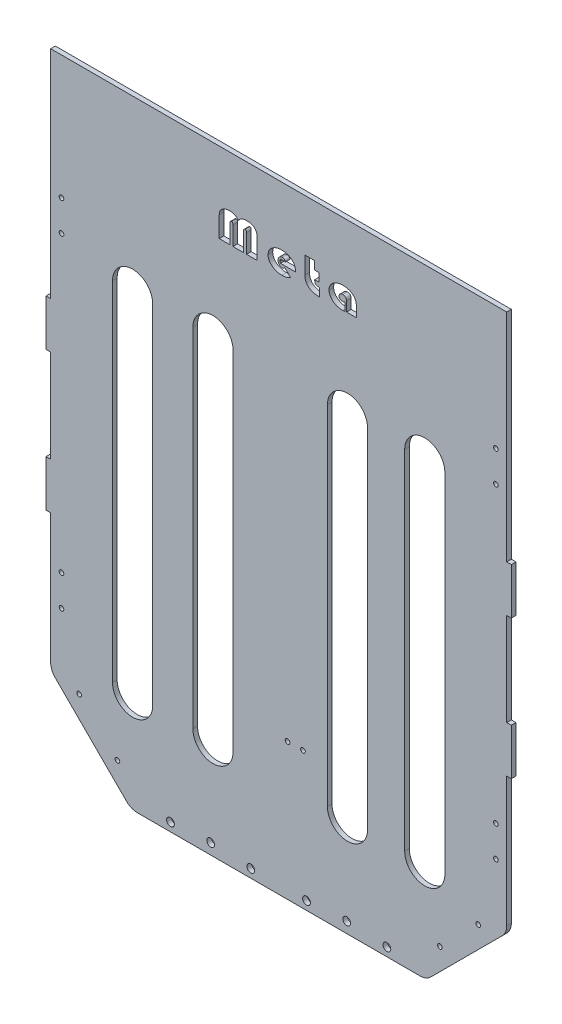
from build123d import *

# Parameters (mm, degrees)
EXTRUDE_1_DEPTH     = 3
CUT_EXTRUDE_2_DEPTH = 4
SKETCH_4_R          = 1.5
CUT_EXTRUDE_3_DEPTH = 4
CUT_EXTRUDE_4_DEPTH = 4
FILLET_3_R          = 10
SKETCH_8_R          = 1.5
CUT_EXTRUDE_5_DEPTH = 4
SKETCH_9_W          = 295
SKETCH_9_H          = 60
EXTRUDE_2_DEPTH     = 3
SKETCH_10_R         = 1.5
CUT_EXTRUDE_6_DEPTH = 10
CUT_EXTRUDE_7_DEPTH = 10
SKETCH_13_R         = 2.5
CUT_EXTRUDE_8_DEPTH = 10


with BuildPart() as part:
    # 草图1 → 凸台-拉伸1 (new body)
    with BuildSketch(Plane.XY):
        Polygon((-147.5, 90), (-150.5, 90), (-150.5, 60), (-147.5, 60), (-147.5, 0), (-150.5, 0), (-150.5, -30), (-147.5, -30), (-147.5, -90), (-147.5, -120), (-147.5, -170), (147.5, -170), (147.5, -120), (147.5, -90), (147.5, -30), (150.5, -30), (150.5, 0), (147.5, 0), (147.5, 60), (150.5, 60), (150.5, 90), (147.5, 90), (147.5, 170), (-147.5, 170), align=None)
    extrude(amount=EXTRUDE_1_DEPTH)

    # 草图3 → 切除-拉伸2 (cut, through all)
    with BuildSketch(Plane.XY.offset(3)):
        Polygon((-147.5, -118), (-95.5, -170), (-147.5, -170), align=None)
        Polygon((147.5, -170), (147.5, -118), (95.5, -170), align=None)
    extrude(amount=-CUT_EXTRUDE_2_DEPTH, mode=Mode.SUBTRACT)

    # 草图4 → 切除-拉伸3 (cut, through all)
    with BuildSketch(Plane.XY.offset(3)):
        with Locations((140.5, 150)):
            Circle(SKETCH_4_R)
        with Locations((140.5, 130)):
            Circle(SKETCH_4_R)
        with Locations((140.5, -60)):
            Circle(SKETCH_4_R)
        with Locations((140.5, -80)):
            Circle(SKETCH_4_R)
        with Locations((-140.5, -80)):
            Circle(SKETCH_4_R)
        with Locations((-140.5, -60)):
            Circle(SKETCH_4_R)
        with Locations((-140.5, 130)):
            Circle(SKETCH_4_R)
        with Locations((-140.5, 150)):
            Circle(SKETCH_4_R)
    extrude(amount=-CUT_EXTRUDE_3_DEPTH, mode=Mode.SUBTRACT)

    # 草图5 → 切除-拉伸4 (cut, through all)
    with BuildSketch(Plane.XY.offset(3)):
        with BuildLine():
            Line((-81.5, 120), (-81.5, -105))
            ThreePointArc((-81.5, -105), (-94.5, -118), (-107.5, -105))
            Line((-107.5, -105), (-107.5, 120))
            ThreePointArc((-107.5, 120), (-94.5, 133), (-81.5, 120))
        make_face()
        with BuildLine():
            Line((-29.5, 120), (-29.5, -105))
            ThreePointArc((-29.5, -105), (-42.5, -118), (-55.5, -105))
            Line((-55.5, -105), (-55.5, 120))
            ThreePointArc((-55.5, 120), (-42.5, 133), (-29.5, 120))
        make_face()
        with BuildLine():
            Line((57.5, 120), (57.5, -105))
            ThreePointArc((57.5, -105), (44.5, -118), (31.5, -105))
            Line((31.5, -105), (31.5, 120))
            ThreePointArc((31.5, 120), (44.5, 133), (57.5, 120))
        make_face()
        with BuildLine():
            Line((107.5, 120), (107.5, -105))
            ThreePointArc((107.5, -105), (94.5, -118), (81.5, -105))
            Line((81.5, -105), (81.5, 120))
            ThreePointArc((81.5, 120), (94.5, 133), (107.5, 120))
        make_face()
    extrude(amount=-CUT_EXTRUDE_4_DEPTH, mode=Mode.SUBTRACT)

    # 圆角3
    fillet_3_edges = [part.edges().sort_by_distance(p)[0] for p in [
        (-147.5, -118, 1.5),
        (-95.5, -170, 1.5),
        (95.5, -170, 1.5),
        (147.5, -118, 1.5),
    ]]
    fillet(fillet_3_edges, radius=FILLET_3_R)

    # 草图8 → 切除-拉伸5 (cut, through all)
    with BuildSketch(Plane.XY.offset(3)):
        with Locations((-129.044105664, -122.313758713)):
            Circle(SKETCH_8_R)
        with Locations((-104.295368322, -147.062496054)):
            Circle(SKETCH_8_R)
        with Locations((104.295368322, -147.062496054)):
            Circle(SKETCH_8_R)
        with Locations((129.044105664, -122.313758713)):
            Circle(SKETCH_8_R)
    extrude(amount=-CUT_EXTRUDE_5_DEPTH, mode=Mode.SUBTRACT)

    # 草图9 → 凸台-拉伸2 (add)
    with BuildSketch(Plane.XY.offset(3)):
        with Locations((0, 200)):
            Rectangle(SKETCH_9_W, SKETCH_9_H)
    extrude(amount=-EXTRUDE_2_DEPTH)

    # 草图10 → 切除-拉伸6 (cut)
    with BuildSketch(Plane(origin=(0, 0, 0), x_dir=(-1, 0, 0), z_dir=(0, 0, -1))):
        with Locations((-15.714480525, -81.497694715)):
            Circle(SKETCH_10_R)
        with Locations((-5.714480525, -81.497694715)):
            Circle(SKETCH_10_R)
    extrude(amount=-CUT_EXTRUDE_6_DEPTH, mode=Mode.SUBTRACT)

    # 草图12 → 切除-拉伸7 (cut)
    with BuildSketch(Plane.XY.offset(3)):
        with BuildLine():
            Line((-38.459270455, 178.142606867), (-38.459270455, 191.48003622))
            add(Edge.make_bspline(
                [(-38.459270455, 191.48003622), (-38.455033411, 191.681058058), (-38.446709584, 192.075972675), (-38.346599974, 192.652647807), (-38.208715022, 193.205847545), (-37.99443122, 193.725817353), (-37.730436968, 194.22146777), (-37.396648893, 194.680992182), (-37.014003649, 195.120623841), (-36.567844802, 195.521180351), (-36.079300876, 195.888824271), (-35.54992644, 196.206329747), (-34.989033735, 196.477067178), (-34.392513082, 196.697756907), (-33.761395822, 196.869228712), (-33.096340243, 196.994280016), (-32.397190688, 197.066282213), (-31.919749742, 197.07520164), (-31.676234956, 197.07975092)],
                knots=[0, 0, 0, 0, 0.000602343, 0.001183325, 0.001751524, 0.002309435, 0.002865829, 0.003432383, 0.004009349, 0.004611332, 0.005227461, 0.005841092, 0.006460048, 0.007093382, 0.007746343, 0.00841978, 0.009121464, 0.009851909, 0.009851909, 0.009851909, 0.009851909], degree=3))
            add(Edge.make_bspline(
                [(-31.676234956, 197.07975092), (-31.385549048, 197.073097088), (-30.820070313, 197.06015322), (-29.99936011, 196.929275852), (-29.228647015, 196.734183589), (-28.5105693, 196.4454009), (-27.844924771, 196.074455011), (-27.231400107, 195.622132358), (-26.670586716, 195.087898147), (-26.348532633, 194.679853549), (-26.184824194, 194.472433903)],
                knots=[0, 0, 0, 0, 0.000871367, 0.001695092, 0.002487058, 0.003252042, 0.00400983, 0.004767182, 0.005533196, 0.006325153, 0.006325153, 0.006325153, 0.006325153], degree=3))
            add(Edge.make_bspline(
                [(-26.184824194, 194.472433903), (-26.009496825, 194.688435518), (-25.666410016, 195.111115131), (-25.074517517, 195.652462415), (-24.448746168, 196.10982807), (-23.770022718, 196.473582165), (-23.028307523, 196.746635702), (-22.214259021, 196.942877484), (-21.321099271, 197.0576227), (-20.699104066, 197.072193956), (-20.376524133, 197.07975092)],
                knots=[0, 0, 0, 0, 0.000833618, 0.001631253, 0.002398327, 0.003153861, 0.003933201, 0.004763076, 0.005661141, 0.006628686, 0.006628686, 0.006628686, 0.006628686], degree=3))
            add(Edge.make_bspline(
                [(-20.376524133, 197.07975092), (-20.123647833, 197.07530343), (-19.631518827, 197.066648057), (-18.915021362, 196.994629219), (-18.244107006, 196.871219331), (-17.618314213, 196.698736696), (-17.038228497, 196.479322271), (-16.504642257, 196.208600824), (-16.014321938, 195.890905499), (-15.573399332, 195.519869728), (-15.176511521, 195.107082453), (-14.838764322, 194.643329349), (-14.547595573, 194.141770012), (-14.315375964, 193.592327554), (-14.128889326, 193.001946764), (-14.005801719, 192.36516806), (-13.920492779, 191.686920679), (-13.913819056, 191.21959361), (-13.910377932, 190.978629101)],
                knots=[0, 0, 0, 0, 0.000758509, 0.001476155, 0.002157478, 0.002802705, 0.003421024, 0.004014812, 0.004594463, 0.005169683, 0.005739974, 0.006307988, 0.006886625, 0.007476007, 0.008093857, 0.008740504, 0.009419154, 0.010141581, 0.010141581, 0.010141581, 0.010141581], degree=3))
            Line((-13.910377932, 190.978629101), (-13.910377932, 178.142606867))
            Line((-13.910377932, 178.142606867), (-20.829796168, 178.142606867))
            Line((-20.829796168, 178.142606867), (-20.829796168, 190.176377712))
            add(Edge.make_bspline(
                [(-20.829796168, 190.176377712), (-20.832218182, 190.300761455), (-20.836681157, 190.529959794), (-20.865105905, 190.844941034), (-20.92112314, 191.100630773), (-20.992727215, 191.306747428), (-21.108032251, 191.465049964), (-21.268895249, 191.570688481), (-21.470616508, 191.637395796), (-21.619396243, 191.641997383), (-21.700238926, 191.644497755)],
                knots=[0, 0, 0, 0, 0.000373241, 0.00068776, 0.000946634, 0.001157445, 0.001337951, 0.001522643, 0.001725599, 0.001967108, 0.001967108, 0.001967108, 0.001967108], degree=3))
            add(Edge.make_bspline(
                [(-21.700238926, 191.644497755), (-21.782353073, 191.641809977), (-21.939142146, 191.636677923), (-22.156487997, 191.566239929), (-22.33931983, 191.453623681), (-22.494902495, 191.301842025), (-22.603414675, 191.097426259), (-22.69003804, 190.857700929), (-22.735018452, 190.572420639), (-22.740332622, 190.369040765), (-22.743165732, 190.260614108)],
                knots=[0, 0, 0, 0, 0.000245507, 0.000468773, 0.000675848, 0.000885741, 0.001112119, 0.001363328, 0.001648212, 0.00197352, 0.00197352, 0.00197352, 0.00197352], degree=3))
            Line((-22.743165732, 190.260614108), (-22.743165732, 178.142606867))
            Line((-22.743165732, 178.142606867), (-29.626482655, 178.142606867))
            Line((-29.626482655, 178.142606867), (-29.626482655, 190.176377712))
            add(Edge.make_bspline(
                [(-29.626482655, 190.176377712), (-29.628871414, 190.296769977), (-29.633287366, 190.519331765), (-29.662498612, 190.82739981), (-29.718086281, 191.082013607), (-29.790903541, 191.290483694), (-29.903421743, 191.459303522), (-30.075245846, 191.566869256), (-30.286817063, 191.63838494), (-30.444052598, 191.642353388), (-30.529015469, 191.644497755)],
                knots=[0, 0, 0, 0, 0.000361214, 0.000667753, 0.000926627, 0.001141183, 0.001328169, 0.001521751, 0.001737391, 0.001990895, 0.001990895, 0.001990895, 0.001990895], degree=3))
            add(Edge.make_bspline(
                [(-30.529015469, 191.644497755), (-30.608533781, 191.64022426), (-30.760134601, 191.632076888), (-30.971623219, 191.560434645), (-31.155274513, 191.447742079), (-31.298121233, 191.277047854), (-31.411515054, 191.065942031), (-31.483286247, 190.807139024), (-31.53288485, 190.507212659), (-31.537425211, 190.291620536), (-31.53985222, 190.176377712)],
                knots=[0, 0, 0, 0, 0.000237885, 0.000453525, 0.000662726, 0.000875928, 0.00111283, 0.001376781, 0.001677492, 0.002022833, 0.002022833, 0.002022833, 0.002022833], degree=3))
            Line((-31.53985222, 190.176377712), (-31.53985222, 178.142606867))
            Line((-31.53985222, 178.142606867), (-38.459270455, 178.142606867))
        make_face()
        with BuildLine():
            Line((10.734784758, 184.103334692), (1.103756825, 184.103334692))
            add(Edge.make_bspline(
                [(1.103756825, 184.103334692), (1.033567019, 184.28570241), (0.895771868, 184.643722875), (0.873841118, 185.026603282), (0.863081408, 185.214452867)],
                knots=[0, 0, 0, 0, 0.000582241, 0.001143042, 0.001143042, 0.001143042, 0.001143042], degree=3))
            add(Edge.make_bspline(
                [(0.863081408, 185.214452867), (0.867020867, 185.317710925), (0.875065676, 185.528575206), (0.939937842, 185.845419118), (1.034879003, 186.170330206), (1.127987471, 186.381323284), (1.17595945, 186.490032576)],
                knots=[0, 0, 0, 0, 0.000309517, 0.000632068, 0.000967098, 0.001323175, 0.001323175, 0.001323175, 0.001323175], degree=3))
            Line((1.17595945, 186.490032576), (4.40903255, 186.490032576))
            add(Edge.make_bspline(
                [(4.40903255, 186.490032576), (4.379994244, 186.610498606), (4.324121546, 186.842287681), (4.171157001, 187.157397132), (3.974707816, 187.426739924), (3.725502588, 187.644119928), (3.432603622, 187.816197993), (3.089036299, 187.928130213), (2.703472325, 188.002976667), (2.430551696, 188.010405098), (2.287077625, 188.014310217)],
                knots=[0, 0, 0, 0, 0.000370819, 0.000713494, 0.001043223, 0.001364349, 0.001698706, 0.002055167, 0.002443016, 0.002872895, 0.002872895, 0.002872895, 0.002872895], degree=3))
            add(Edge.make_bspline(
                [(2.287077625, 188.014310217), (2.102841006, 188.004309983), (1.744079765, 187.984836676), (1.228792549, 187.831108161), (0.763495866, 187.57400253), (0.360541365, 187.217873486), (0.023360862, 186.789426315), (-0.214586267, 186.287683856), (-0.36407772, 185.728416025), (-0.380116372, 185.334448194), (-0.38843076, 185.130216471)],
                knots=[0, 0, 0, 0, 0.000552011, 0.001074922, 0.001597388, 0.002134731, 0.002677927, 0.003221523, 0.003789721, 0.00440133, 0.00440133, 0.00440133, 0.00440133], degree=3))
            add(Edge.make_bspline(
                [(-0.38843076, 185.130216471), (-0.381548459, 184.921983889), (-0.368231671, 184.519067849), (-0.220294667, 183.946312068), (0.002697873, 183.424171714), (0.273450006, 183.045892005), (0.525336039, 182.780774821), (0.730740292, 182.610656952), (0.942719735, 182.456924303), (1.174921704, 182.342781536), (1.417585579, 182.248684416), (1.673080959, 182.181348473), (1.942046639, 182.139262938), (2.125129518, 182.135655103), (2.218886256, 182.133807531)],
                knots=[0, 0, 0, 0, 0.000623309, 0.00120606, 0.001762816, 0.002318183, 0.002590536, 0.00285812, 0.003117397, 0.00337393, 0.003631682, 0.003897305, 0.004165069, 0.004446115, 0.004446115, 0.004446115, 0.004446115], degree=3))
            add(Edge.make_bspline(
                [(2.218886256, 182.133807531), (2.379221698, 182.142819521), (2.704058408, 182.161077652), (3.177410779, 182.32130588), (3.641972272, 182.563337686), (3.916891781, 182.792603593), (4.060053196, 182.911991379)],
                knots=[0, 0, 0, 0, 0.00047976, 0.000971986, 0.001485192, 0.002042814, 0.002042814, 0.002042814, 0.002042814], degree=3))
            Line((4.060053196, 182.911991379), (7.678206963, 179.418186577))
            add(Edge.make_bspline(
                [(7.678206963, 179.418186577), (7.467308981, 179.29210475), (7.047952024, 179.041399218), (6.389257308, 178.720237532), (5.712777007, 178.44645517), (5.014242628, 178.227828043), (4.300308464, 178.04633274), (3.56407752, 177.932037365), (2.810412846, 177.849440111), (2.300685878, 177.841682413), (2.042390951, 177.837751339)],
                knots=[0, 0, 0, 0, 0.00073686, 0.001465199, 0.00219592, 0.002924093, 0.003659587, 0.004403445, 0.005157412, 0.005931959, 0.005931959, 0.005931959, 0.005931959], degree=3))
            add(Edge.make_bspline(
                [(2.042390951, 177.837751339), (1.738584123, 177.843588191), (1.140105476, 177.85508639), (0.260903717, 177.95565816), (-0.58564139, 178.107590854), (-1.393349226, 178.335870055), (-2.168881585, 178.618099678), (-2.904463359, 178.975786528), (-3.609536209, 179.388426691), (-4.270665778, 179.861945745), (-4.872054854, 180.384481685), (-5.407040088, 180.937101634), (-5.855538948, 181.525499891), (-6.21876182, 182.144972156), (-6.507740924, 182.791117046), (-6.713180963, 183.469948005), (-6.836063698, 184.180419147), (-6.85101483, 184.66442677), (-6.858588217, 184.909597339)],
                knots=[0, 0, 0, 0, 0.000911121, 0.001794845, 0.002651613, 0.003488582, 0.004309715, 0.005124237, 0.005938769, 0.006758058, 0.007559928, 0.008325942, 0.009061622, 0.009773651, 0.010475805, 0.011180063, 0.011896227, 0.012631382, 0.012631382, 0.012631382, 0.012631382], degree=3))
            add(Edge.make_bspline(
                [(-6.858588217, 184.909597339), (-6.851139489, 185.152132739), (-6.836435518, 185.630903523), (-6.711610562, 186.333818162), (-6.512111198, 187.007942647), (-6.226124507, 187.651751778), (-5.864837565, 188.269323073), (-5.414779349, 188.851472348), (-4.887342399, 189.404300735), (-4.290528504, 189.924721331), (-3.632467908, 190.401038747), (-2.924162874, 190.810848402), (-2.182922609, 191.170944162), (-1.397058448, 191.450855229), (-0.575065449, 191.680694666), (0.287844617, 191.830865084), (1.188240445, 191.932570938), (1.801417959, 191.943679614), (2.114593576, 191.949353283)],
                knots=[0, 0, 0, 0, 0.000727145, 0.001435401, 0.002134661, 0.002831524, 0.003543553, 0.004276045, 0.00503362, 0.005832465, 0.006648497, 0.007466488, 0.008284627, 0.009117057, 0.009965626, 0.01084212, 0.011741795, 0.012680978, 0.012680978, 0.012680978, 0.012680978], degree=3))
            add(Edge.make_bspline(
                [(2.114593576, 191.949353283), (2.413016783, 191.943171643), (2.999283313, 191.93102752), (3.861363209, 191.835823509), (4.689612083, 191.685883553), (5.48210712, 191.469868701), (6.236698972, 191.186249686), (6.957127269, 190.843964278), (7.645850792, 190.444151622), (8.286130806, 189.979591571), (8.874399385, 189.475354951), (9.390501055, 188.93326316), (9.828419277, 188.359268437), (10.188017643, 187.755568538), (10.467379886, 187.121122526), (10.665047341, 186.45696591), (10.783872311, 185.761578959), (10.799198106, 185.287121346), (10.806987383, 185.045980075)],
                knots=[0, 0, 0, 0, 0.000895086, 0.001758438, 0.002598699, 0.003418066, 0.004219002, 0.005013859, 0.005808463, 0.006604442, 0.00738368, 0.008129914, 0.008845538, 0.009545166, 0.01023307, 0.010919652, 0.011619326, 0.012342466, 0.012342466, 0.012342466, 0.012342466], degree=3))
            add(Edge.make_bspline(
                [(10.806987383, 185.045980075), (10.805757983, 185.012548107), (10.80216542, 184.914852904), (10.789711094, 184.72352248), (10.763926251, 184.442977373), (10.745340254, 184.226358485), (10.734784758, 184.103334692)],
                knots=[0, 0, 0, 0, 0.000100362, 0.000293278, 0.000575095, 0.000945523, 0.000945523, 0.000945523, 0.000945523], degree=3))
        make_face()
        with BuildLine():
            Line((23.302052776, 196.634501398), (23.302052776, 191.339642227))
            Line((23.302052776, 191.339642227), (26.154056466, 191.339642227))
            Line((26.154056466, 191.339642227), (26.154056466, 185.988625458))
            Line((26.154056466, 185.988625458), (23.302052776, 185.988625458))
            add(Edge.make_bspline(
                [(23.302052776, 185.988625458), (23.302676145, 185.86016815), (23.303879633, 185.612166009), (23.338675734, 185.25618393), (23.384015338, 184.929925918), (23.451950808, 184.635840529), (23.538686637, 184.372774444), (23.649148701, 184.142858434), (23.771004772, 183.937448871), (23.924520518, 183.76688753), (24.099948214, 183.616088257), (24.314767783, 183.499952661), (24.553697021, 183.388120403), (24.831664641, 183.30781928), (25.139143066, 183.2371329), (25.483584423, 183.198811382), (25.859127699, 183.161990174), (26.121850226, 183.161134092), (26.258349147, 183.160689309)],
                knots=[0, 0, 0, 0, 0.000385164, 0.000743605, 0.001072063, 0.00137272, 0.001647982, 0.001900977, 0.00213696, 0.002361483, 0.002586436, 0.002827245, 0.003091166, 0.003376643, 0.003692947, 0.004036747, 0.004415169, 0.004824395, 0.004824395, 0.004824395, 0.004824395], degree=3))
            Line((26.258349147, 183.160689309), (26.258349147, 177.837751339))
            add(Edge.make_bspline(
                [(26.258349147, 177.837751339), (25.902451033, 177.843729364), (25.21080144, 177.85534701), (24.203335748, 177.95050941), (23.253771848, 178.097098894), (22.366016703, 178.321283953), (21.533986816, 178.59414004), (20.764376476, 178.938505499), (20.050015166, 179.33725223), (19.403081104, 179.804817579), (18.822075887, 180.325811782), (18.318680876, 180.903316083), (17.886314877, 181.529238238), (17.544078088, 182.21346556), (17.266267356, 182.944648075), (17.076865497, 183.73032621), (16.963681125, 184.566667744), (16.948163265, 185.140547772), (16.940199256, 185.435071999)],
                knots=[0, 0, 0, 0, 0.001067477, 0.002074526, 0.003033376, 0.003946904, 0.004818344, 0.005656937, 0.006472407, 0.007268386, 0.00804657, 0.008808434, 0.009561665, 0.010322292, 0.011097877, 0.011903421, 0.012741313, 0.0136247, 0.0136247, 0.0136247, 0.0136247], degree=3))
            Line((16.940199256, 185.435071999), (16.940199256, 196.634501398))
            Line((16.940199256, 196.634501398), (23.302052776, 196.634501398))
        make_face()
        with BuildLine():
            Line((42.909076739, 183.160689309), (42.909076739, 177.950066534))
            add(Edge.make_bspline(
                [(42.909076739, 177.950066534), (42.675457841, 177.917309033), (42.203076528, 177.85107282), (41.72614355, 177.84222395), (41.485080523, 177.837751339)],
                knots=[0, 0, 0, 0, 0.000707006, 0.001429578, 0.001429578, 0.001429578, 0.001429578], degree=3))
            add(Edge.make_bspline(
                [(41.485080523, 177.837751339), (41.173261624, 177.843588189), (40.560130153, 177.855065225), (39.662123904, 177.954960231), (38.801043911, 178.107729374), (37.982432106, 178.335238955), (37.198708019, 178.617310717), (36.459054042, 178.975104666), (35.75409638, 179.386313364), (35.099700013, 179.862253855), (34.506333682, 180.384609815), (33.978508076, 180.936917114), (33.540256105, 181.528214621), (33.173786989, 182.142772558), (32.895864677, 182.7925238), (32.694002739, 183.470425296), (32.570352818, 184.180394032), (32.555515685, 184.664418326), (32.548000042, 184.909597339)],
                knots=[0, 0, 0, 0, 0.000935174, 0.001838838, 0.002707439, 0.003556007, 0.004384669, 0.005202809, 0.006017341, 0.006830123, 0.00762595, 0.008386441, 0.009117293, 0.009829323, 0.01052826, 0.011231364, 0.011947528, 0.012682683, 0.012682683, 0.012682683, 0.012682683], degree=3))
            add(Edge.make_bspline(
                [(32.548000042, 184.909597339), (32.555533223, 185.148101986), (32.570402296, 185.618865015), (32.694284078, 186.311898359), (32.900613219, 186.978079416), (33.186677398, 187.617475558), (33.552228728, 188.230411734), (34.001869294, 188.814516823), (34.533963166, 189.370927465), (35.137068542, 189.896650747), (35.7949448, 190.377871195), (36.497960903, 190.795170024), (37.228443978, 191.155962615), (37.996860021, 191.443435139), (38.795434296, 191.674653566), (39.6295565, 191.832321186), (40.494551927, 191.931760768), (41.082340682, 191.94342886), (41.380787842, 191.949353283)],
                knots=[0, 0, 0, 0, 0.00071513, 0.00141153, 0.002104283, 0.002802772, 0.003507898, 0.004240389, 0.005009306, 0.00581381, 0.006637799, 0.007450928, 0.008263591, 0.009078617, 0.009908957, 0.010754647, 0.011622424, 0.01251751, 0.01251751, 0.01251751, 0.01251751], degree=3))
            add(Edge.make_bspline(
                [(41.380787842, 191.949353283), (41.713969915, 191.945007112), (42.364309838, 191.936523798), (43.311539776, 191.840286705), (44.20635001, 191.69492213), (45.046813282, 191.487351444), (45.833605003, 191.218000087), (46.566799012, 190.889834425), (47.245111197, 190.498108192), (47.867246824, 190.05037072), (48.423880934, 189.54876774), (48.916626698, 189.005582143), (49.326218114, 188.410214389), (49.668246636, 187.774340554), (49.921654589, 187.089555786), (50.11334406, 186.36633027), (50.226816889, 185.596435014), (50.239286442, 185.067750176), (50.245665697, 184.797282144)],
                knots=[0, 0, 0, 0, 0.000999198, 0.001950339, 0.002853122, 0.003717033, 0.004544111, 0.005344837, 0.00612299, 0.006890063, 0.007639922, 0.008367122, 0.009084823, 0.009802602, 0.010527487, 0.01126984, 0.012044179, 0.012855257, 0.012855257, 0.012855257, 0.012855257], degree=3))
            Line((50.245665697, 184.797282144), (50.245665697, 178.142606867))
            Line((50.245665697, 178.142606867), (43.883812178, 178.142606867))
            Line((43.883812178, 178.142606867), (43.883812178, 184.436269019))
            add(Edge.make_bspline(
                [(43.883812178, 184.436269019), (43.87729152, 184.60825897), (43.864819787, 184.937215444), (43.737254904, 185.402508045), (43.524945941, 185.808826281), (43.232610351, 186.153661146), (42.87229876, 186.426537186), (42.457556672, 186.628581667), (41.987378598, 186.745023599), (41.656879835, 186.759358014), (41.485080523, 186.766809306)],
                knots=[0, 0, 0, 0, 0.000515005, 0.000985025, 0.001433587, 0.001880423, 0.002329702, 0.00278, 0.003255736, 0.003770741, 0.003770741, 0.003770741, 0.003770741], degree=3))
            add(Edge.make_bspline(
                [(41.485080523, 186.766809306), (41.322614358, 186.76049726), (41.004265738, 186.748128956), (40.544673401, 186.632280132), (40.121225276, 186.441260151), (39.744611339, 186.181185475), (39.422835688, 185.877198446), (39.192493192, 185.5249064), (39.040438353, 185.144817332), (39.025614971, 184.876241786), (39.018157499, 184.741124547)],
                knots=[0, 0, 0, 0, 0.000486703, 0.000953683, 0.001411476, 0.001873206, 0.002321391, 0.002729693, 0.003128284, 0.003531829, 0.003531829, 0.003531829, 0.003531829], degree=3))
            add(Edge.make_bspline(
                [(39.018157499, 184.741124547), (39.024978579, 184.607644156), (39.038324975, 184.346471083), (39.170443282, 183.975893431), (39.380196412, 183.642003992), (39.672866887, 183.354719983), (40.030283413, 183.117028127), (40.448304444, 182.949964318), (40.915347527, 182.841630092), (41.245088285, 182.83250784), (41.416889154, 182.827754983)],
                knots=[0, 0, 0, 0, 0.000399135, 0.000780964, 0.001164915, 0.001573354, 0.002001677, 0.002444153, 0.002917091, 0.003431533, 0.003431533, 0.003431533, 0.003431533], degree=3))
            add(Edge.make_bspline(
                [(41.416889154, 182.827754983), (41.548221143, 182.831146116), (41.808490059, 182.837866539), (42.190212561, 182.905561278), (42.559723073, 183.008053725), (42.792446634, 183.109732626), (42.909076739, 183.160689309)],
                knots=[0, 0, 0, 0, 0.000393614, 0.000780051, 0.001159682, 0.001541068, 0.001541068, 0.001541068, 0.001541068], degree=3))
        make_face()
    extrude(amount=-CUT_EXTRUDE_7_DEPTH, mode=Mode.SUBTRACT)

    # 草图13 → 切除-拉伸8 (cut)
    with BuildSketch(Plane.XY.offset(3)):
        with Locations((-18, -164.5)):
            Circle(SKETCH_13_R)
        with Locations((-70, -164.5)):
            Circle(SKETCH_13_R)
        with Locations((-44, -163)):
            Circle(SKETCH_13_R)
        with Locations((70, -164.5)):
            Circle(SKETCH_13_R)
        with Locations((44, -163)):
            Circle(SKETCH_13_R)
        with Locations((18, -164.5)):
            Circle(SKETCH_13_R)
    extrude(amount=-CUT_EXTRUDE_8_DEPTH, mode=Mode.SUBTRACT)


solid = part.part
